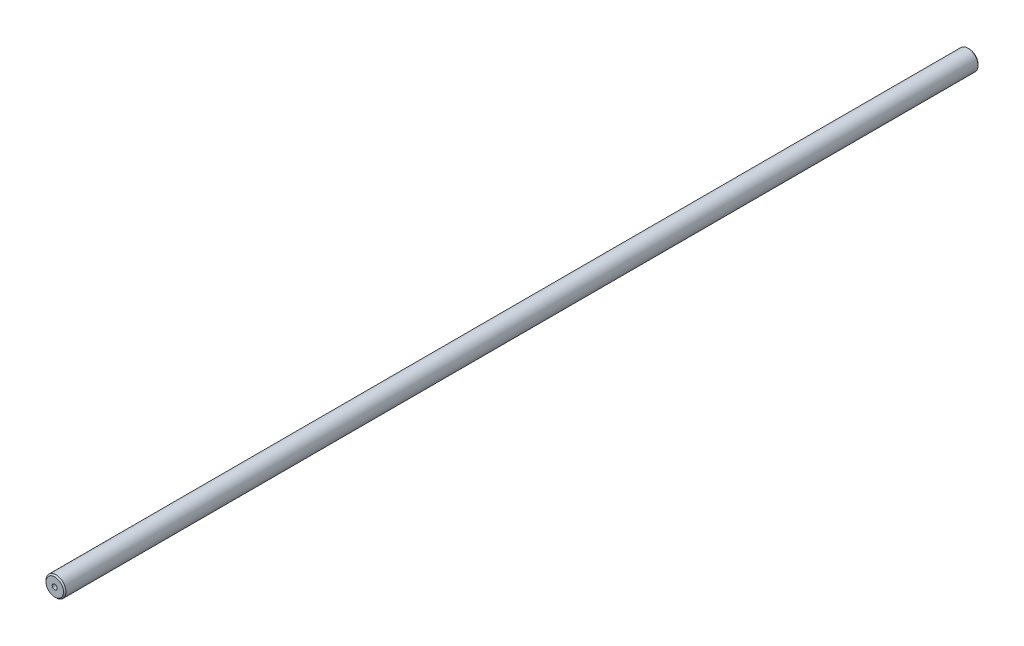
from build123d import *

# Parameters (mm, degrees)
SKETCH1_R           = 4
BOSS_EXTRUDE1_DEPTH = 366
SKETCH2_R           = 1
CUT_EXTRUDE1_DEPTH  = 10
CHAMFER1_SIZE       = 0.5


with BuildPart() as part:
    # Sketch1 → Boss-Extrude1 (new body)
    with BuildSketch(Plane.XY):
        Circle(SKETCH1_R)
    extrude(amount=BOSS_EXTRUDE1_DEPTH)

    # Sketch2 → Cut-Extrude1 (cut)
    with BuildSketch(Plane.XY.offset(366)):
        Circle(SKETCH2_R)
    extrude(amount=-CUT_EXTRUDE1_DEPTH, mode=Mode.SUBTRACT)

    # Chamfer1
    chamfer1_edges = [part.edges().sort_by_distance(p)[0] for p in [
        (-4, 0, 0),
        (-4, 0, 366),
    ]]
    chamfer(chamfer1_edges, length=CHAMFER1_SIZE)


solid = part.part
